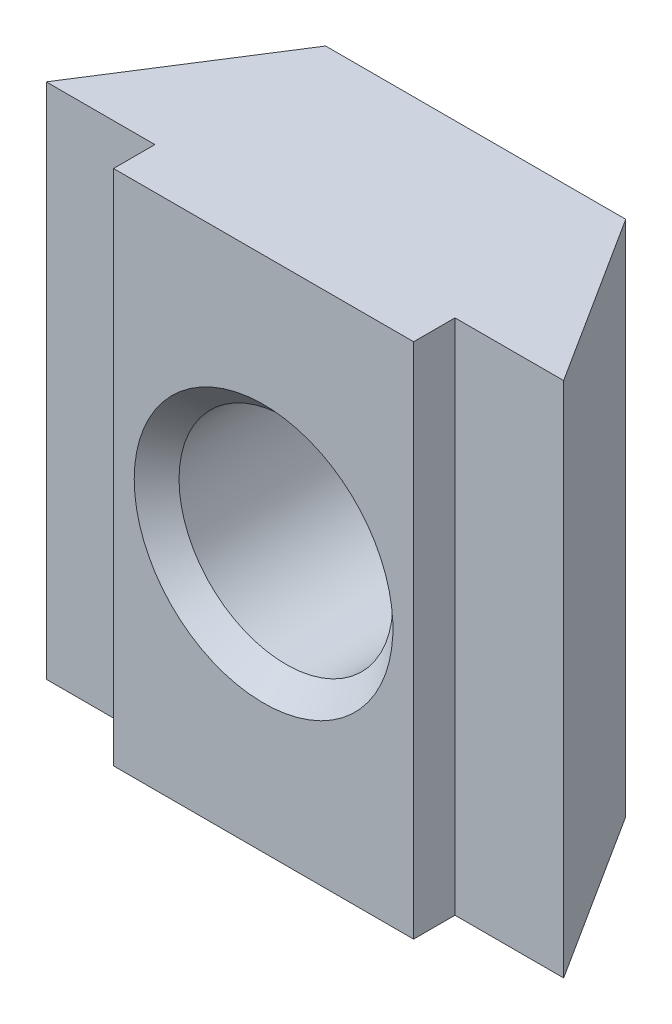
from build123d import *

# Parameters (mm, degrees)
EXTRUDE1_DEPTH = 10
SKETCH2_W      = 5.8
SKETCH2_H      = 10
EXTRUDE2_DEPTH = 0.8
HOLEWZD1_D     = 4.134
HOLEWZD1_DEPTH = 4.1
CHAMFER1_SIZE  = 0.433


with BuildPart() as part:
    # Sketch1 → Extrude1 (new body)
    with BuildSketch(Plane.XZ.offset(-23.4)):
        Polygon((-13.1, -10.8), (-11, -7.5), (-21, -7.5), (-18.9, -10.8), align=None)
    extrude(amount=-EXTRUDE1_DEPTH)

    # Sketch2 → Extrude2 (add)
    with BuildSketch(Plane.XY.offset(-7.5)):
        with Locations((-16, 28.4)):
            Rectangle(SKETCH2_W, SKETCH2_H)
    extrude(amount=EXTRUDE2_DEPTH)

    # HoleWzd1
    with Locations(Plane.XY.offset(-6.7)):
        with Locations((-16, 28.4)):
            Hole(HOLEWZD1_D / 2, depth=HOLEWZD1_DEPTH)

    # Chamfer1
    chamfer1_edges = [part.edges().sort_by_distance(p)[0] for p in [
        (-13.933, 28.4, -6.7),
        (-13.933, 28.4, -10.8),
    ]]
    chamfer(chamfer1_edges, length=CHAMFER1_SIZE)


solid = part.part
